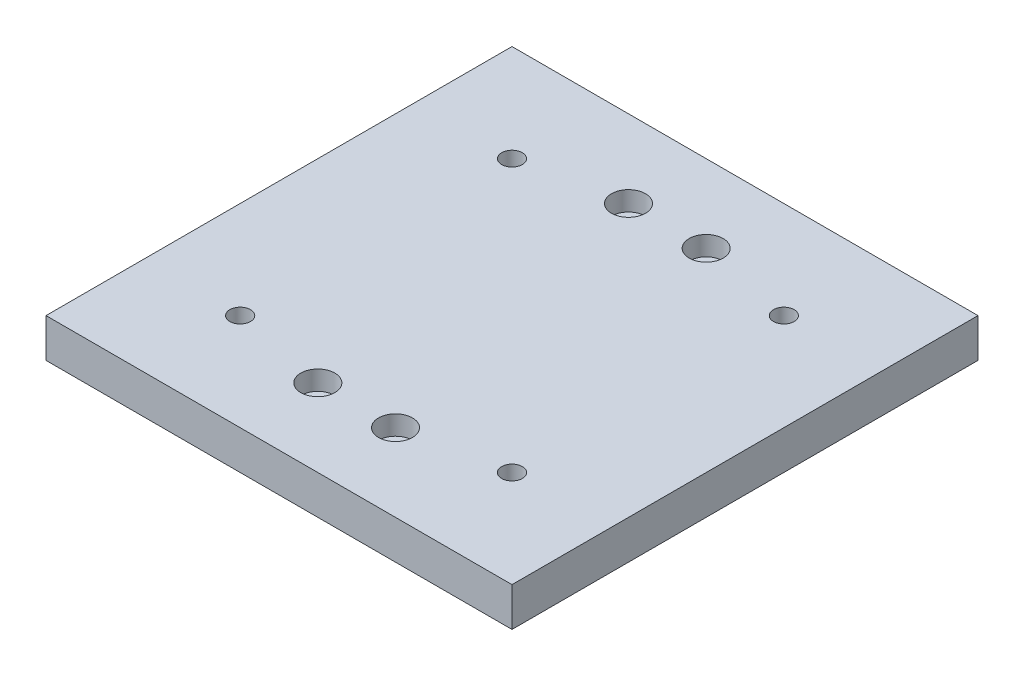
from build123d import *

# Parameters (mm, degrees)
SKETCH1_W                                        = 152.4
SKETCH1_H                                        = 152.4
BOSS_EXTRUDE1_DEPTH                              = 12.7
CBORE_FOR_1_4_SOCKET_HEAD_CAP_SCREW1_D           = 6.7564
CBORE_FOR_1_4_SOCKET_HEAD_CAP_SCREW1_CBORE_D     = 11.1125
CBORE_FOR_1_4_SOCKET_HEAD_CAP_SCREW1_CBORE_DEPTH = 6.35
CBORE_FOR_1_4_SOCKET_HEAD_CAP_SCREW2_D           = 6.7564
CBORE_FOR_1_4_SOCKET_HEAD_CAP_SCREW2_CBORE_D     = 11.1125
CBORE_FOR_1_4_SOCKET_HEAD_CAP_SCREW2_CBORE_DEPTH = 6.35


with BuildPart() as part:
    # Sketch1 → Boss-Extrude1 (new body)
    with BuildSketch(Plane(origin=(0, 0, 0), x_dir=(1, 0, 0), z_dir=(0, 1, 0))):
        Rectangle(SKETCH1_W, SKETCH1_H)
    extrude(amount=BOSS_EXTRUDE1_DEPTH)

    # CBORE for 1/4 Socket Head Cap Screw1 (through all)
    with Locations(Plane(origin=(0, 12.7, 0), x_dir=(1, 0, 0), z_dir=(0, 1, 0))):
        with Locations((-12.7, -50.8), (12.7, -50.8), (12.7, 50.8), (-12.7, 50.8)):
            CounterBoreHole(CBORE_FOR_1_4_SOCKET_HEAD_CAP_SCREW1_D / 2, CBORE_FOR_1_4_SOCKET_HEAD_CAP_SCREW1_CBORE_D / 2, CBORE_FOR_1_4_SOCKET_HEAD_CAP_SCREW1_CBORE_DEPTH)

    # CBORE for 1/4 Socket Head Cap Screw2 (through all)
    with Locations(Plane(origin=(0, 0, 0), x_dir=(-1, 0, 0), z_dir=(0, -1, 0))):
        with Locations((-44.45, -44.45), (-44.45, 44.45), (44.45, 44.45), (44.45, -44.45)):
            CounterBoreHole(CBORE_FOR_1_4_SOCKET_HEAD_CAP_SCREW2_D / 2, CBORE_FOR_1_4_SOCKET_HEAD_CAP_SCREW2_CBORE_D / 2, CBORE_FOR_1_4_SOCKET_HEAD_CAP_SCREW2_CBORE_DEPTH)


solid = part.part
